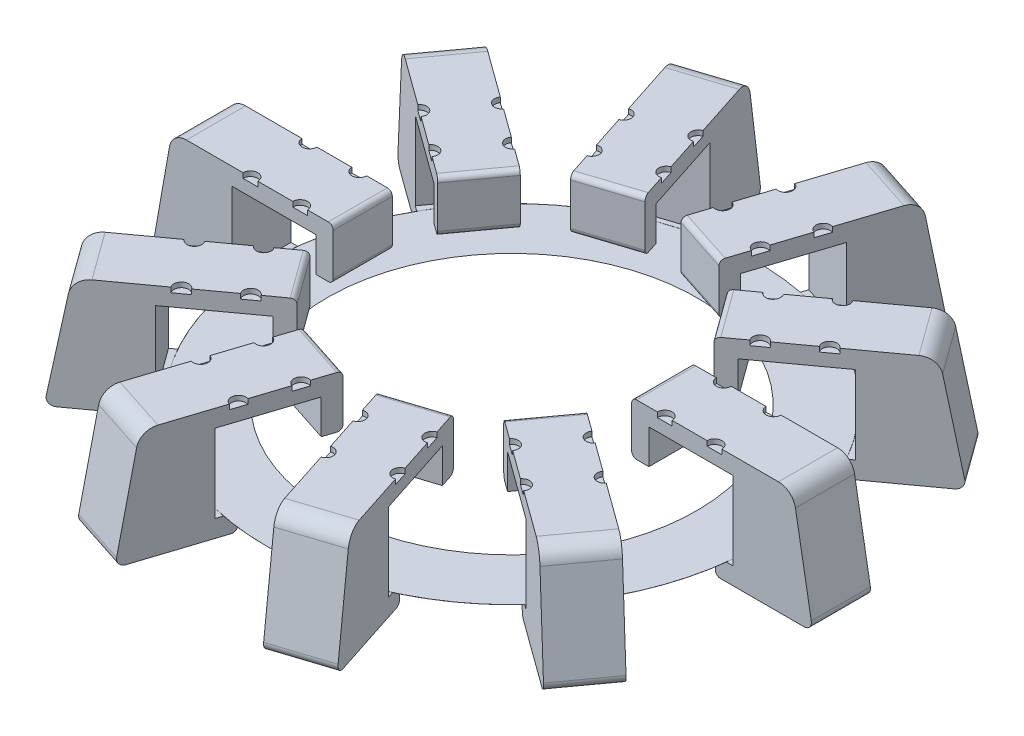
from build123d import *

# Parameters (mm, degrees)
BOSS_EXTRUDE1_DEPTH = 6
SKETCH4_R           = 1.5
CUT_EXTRUDE1_DEPTH  = 1
SKETCH5_R           = 49.89
SKETCH5_R_2         = 37.5
BOSS_EXTRUDE2_DEPTH = 0.0001
CIRPATTERN2_COUNT   = 10


with BuildPart() as part:
    # Sketch1 → Boss-Extrude1 (new body, symmetric)
    with BuildSketch(Plane.XY):
        with BuildLine():
            Line((-33.8, 8.9), (-31.3, 8.9))
            ThreePointArc((-31.3, 8.9), (-30.592893219, 9.192893219), (-30.3, 9.9))
            Line((-30.3, 9.9), (-30.3, 18.4))
            ThreePointArc((-30.3, 18.4), (-30.592893219, 19.107106781), (-31.3, 19.4))
            Line((-31.3, 19.4), (-60.112893822, 19.4))
            ThreePointArc((-60.112893822, 19.4), (-62.362650455, 18.581155551), (-63.559720957, 16.507768622))
            Line((-63.559720957, 16.507768622), (-66.77721163, -1.739527733))
            ThreePointArc((-66.77721163, -1.739527733), (-66.449066665, -2.964181415), (-65.3, -3.5))
            Line((-65.3, -3.5), (-48.29, -3.5))
            ThreePointArc((-48.29, -3.5), (-47.582893219, -3.207106781), (-47.29, -2.5))
            Line((-47.29, -2.5), (-47.29, 0))
            Line((-47.29, 0), (-50.89, 0))
            Line((-50.89, 0), (-50.89, 15.9))
            Line((-50.89, 15.9), (-33.8, 15.9))
            Line((-33.8, 15.9), (-33.8, 8.9))
        make_face()
    boss_extrude1 = extrude(amount=BOSS_EXTRUDE1_DEPTH, both=True)

    # Sketch4 → Cut-Extrude1 (cut)
    with BuildSketch(Plane(origin=(0, 19.4, 0), x_dir=(1, 0, 0), z_dir=(0, 1, 0))):
        with Locations((-37.016888038, 6)):
            Circle(SKETCH4_R)
        with Locations((-37.016888038, -6)):
            Circle(SKETCH4_R)
        with Locations((-47.11952886, 6)):
            Circle(SKETCH4_R)
        with Locations((-47.11952886, -6)):
            Circle(SKETCH4_R)
    cut_extrude1 = extrude(amount=-CUT_EXTRUDE1_DEPTH, mode=Mode.SUBTRACT)

    # Sketch5 → Boss-Extrude2 (add)
    with BuildSketch(Plane(origin=(0, 0, 0), x_dir=(1, 0, 0), z_dir=(0, 1, 0))):
        Circle(SKETCH5_R)
        Circle(SKETCH5_R_2, mode=Mode.SUBTRACT)
    extrude(amount=BOSS_EXTRUDE2_DEPTH)

    # CirPattern2: Boss-Extrude1, Cut-Extrude1 ×10 about axis
    cirpattern2_axis = Axis((0, 0, 0), (0, 1, 0))
    for i in range(1, CIRPATTERN2_COUNT):
        add(boss_extrude1.rotate(cirpattern2_axis, i * 360 / CIRPATTERN2_COUNT))
        add(cut_extrude1.rotate(cirpattern2_axis, i * 360 / CIRPATTERN2_COUNT), mode=Mode.SUBTRACT)


solid = part.part
